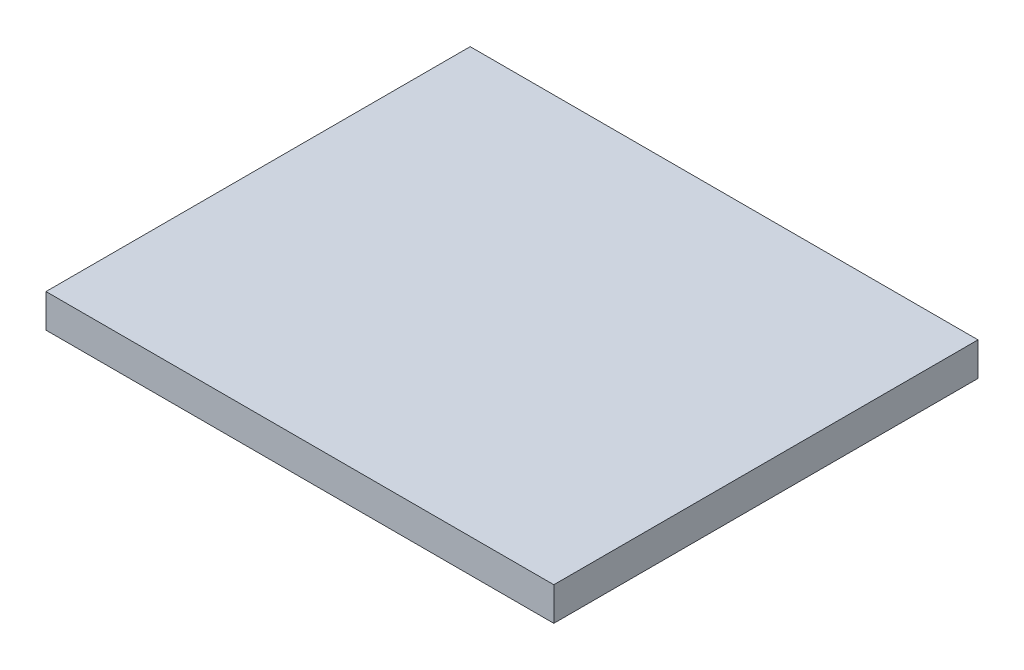
from build123d import *

# Parameters (mm, degrees)
SKETCH2_W           = 8.5
SKETCH2_H           = 7.1
BOSS_EXTRUDE1_DEPTH = 0.56


with BuildPart() as part:
    # Sketch2 → Boss-Extrude1 (new body)
    with BuildSketch(Plane(origin=(0, 0, 0), x_dir=(1, 0, 0), z_dir=(0, 1, 0))):
        with Locations((-5.890928619, -0.908352949)):
            Rectangle(SKETCH2_W, SKETCH2_H)
    extrude(amount=BOSS_EXTRUDE1_DEPTH)


solid = part.part
